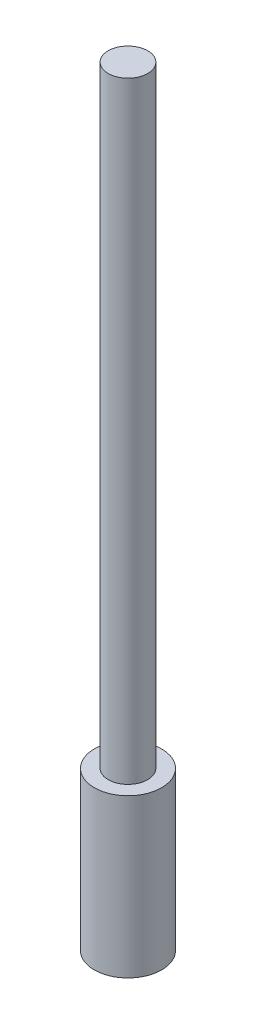
from build123d import *

# Parameters (mm, degrees)
SKETCH1_R           = 8.525
BOSS_EXTRUDE1_DEPTH = 40
SKETCH2_R           = 5
BOSS_EXTRUDE2_DEPTH = 155


with BuildPart() as part:
    # Sketch1 → Boss-Extrude1 (new body)
    with BuildSketch(Plane(origin=(0, 0, 0), x_dir=(1, 0, 0), z_dir=(0, 1, 0))):
        Circle(SKETCH1_R)
    extrude(amount=BOSS_EXTRUDE1_DEPTH)

    # Sketch2 → Boss-Extrude2 (add)
    with BuildSketch(Plane(origin=(0, 40, 0), x_dir=(1, 0, 0), z_dir=(0, 1, 0))):
        Circle(SKETCH2_R)
    extrude(amount=BOSS_EXTRUDE2_DEPTH)


solid = part.part
